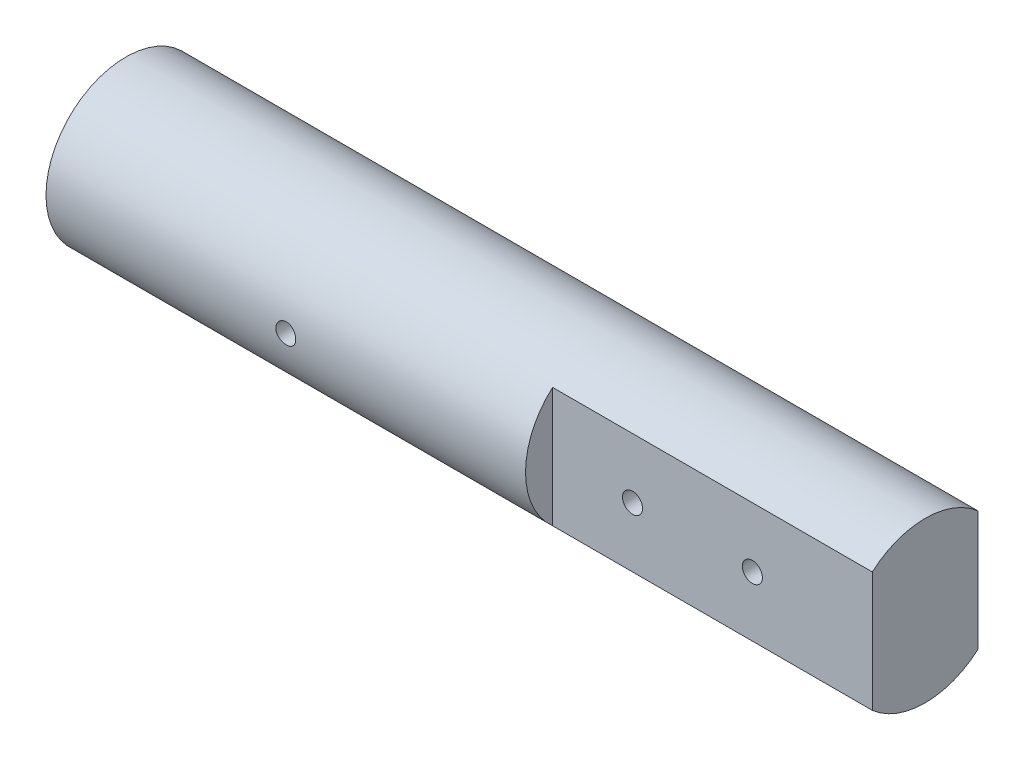
from build123d import *

# Parameters (mm, degrees)
SKETCH1_W                           = 60
SKETCH1_H                           = 10
BOSS_EXTRUDE1_DEPTH                 = 40
M3X0_5_TAPPED_HOLE3_D               = 2.5
M3X0_5_TAPPED_HOLE3_DEPTH           = 10
M3X0_5_TAPPED_HOLE3_TIP             = 0.751075774
M3X0_5_TAPPED_HOLE2_D               = 2.5
M3X0_5_TAPPED_HOLE2_DEPTH           = 5
M3X0_5_TAPPED_HOLE2_TIP             = 0.751075774
M3X0_5_TAPPED_HOLE2_ON_FACE_2_D     = 2.5
M3X0_5_TAPPED_HOLE2_ON_FACE_2_DEPTH = 5
M3X0_5_TAPPED_HOLE2_ON_FACE_2_TIP   = 0.751075774


with BuildPart() as part:
    # Sketch1 → Revolve1 (revolve)
    with BuildSketch(Plane.XY):
        with Locations((30, 5)):
            Rectangle(SKETCH1_W, SKETCH1_H)
    revolve(axis=Axis((0, 0, 0), (1, 0, 0)))

    # Sketch3 → Boss-Extrude1 (add)
    with BuildSketch(Plane(origin=(60, 0, 0), x_dir=(0, 0, -1), z_dir=(1, 0, 0))):
        with BuildLine():
            Line((-6.614378278, -7.5), (-6.614378278, 7.5))
            ThreePointArc((-6.614378278, 7.5), (0, 10), (6.614378278, 7.5))
            Line((6.614378278, 7.5), (6.614378278, -7.5))
            ThreePointArc((6.614378278, -7.5), (0, -10), (-6.614378278, -7.5))
        make_face()
    extrude(amount=BOSS_EXTRUDE1_DEPTH)

    # M3x0.5 Tapped Hole3
    with Locations(Plane.XY.offset(10)):
        with Locations((30, 0)):
            Hole(M3X0_5_TAPPED_HOLE3_D / 2, depth=M3X0_5_TAPPED_HOLE3_DEPTH)
            with Locations((0, 0, -(M3X0_5_TAPPED_HOLE3_DEPTH + M3X0_5_TAPPED_HOLE3_TIP / 2))):  # 118° drill point
                Cone(0, M3X0_5_TAPPED_HOLE3_D / 2, M3X0_5_TAPPED_HOLE3_TIP, mode=Mode.SUBTRACT)

    # M3x0.5 Tapped Hole2
    with Locations(Plane(origin=(70, 0, 6.614378278), x_dir=(1, 0, 0), z_dir=(0, 0, 1))):
        with Locations((0, 0), (15, 0)):
            Hole(M3X0_5_TAPPED_HOLE2_D / 2, depth=M3X0_5_TAPPED_HOLE2_DEPTH)
            with Locations((0, 0, -(M3X0_5_TAPPED_HOLE2_DEPTH + M3X0_5_TAPPED_HOLE2_TIP / 2))):  # 118° drill point
                Cone(0, M3X0_5_TAPPED_HOLE2_D / 2, M3X0_5_TAPPED_HOLE2_TIP, mode=Mode.SUBTRACT)

    # M3x0.5 Tapped Hole2 on face 2
    with Locations(Plane(origin=(85, 0, -6.614378278), x_dir=(-1, 0, 0), z_dir=(0, 0, -1))):
        with Locations((0, 0), (15, 0)):
            Hole(M3X0_5_TAPPED_HOLE2_ON_FACE_2_D / 2, depth=M3X0_5_TAPPED_HOLE2_ON_FACE_2_DEPTH)
            with Locations((0, 0, -(M3X0_5_TAPPED_HOLE2_ON_FACE_2_DEPTH + M3X0_5_TAPPED_HOLE2_ON_FACE_2_TIP / 2))):  # 118° drill point
                Cone(0, M3X0_5_TAPPED_HOLE2_ON_FACE_2_D / 2, M3X0_5_TAPPED_HOLE2_ON_FACE_2_TIP, mode=Mode.SUBTRACT)


solid = part.part
